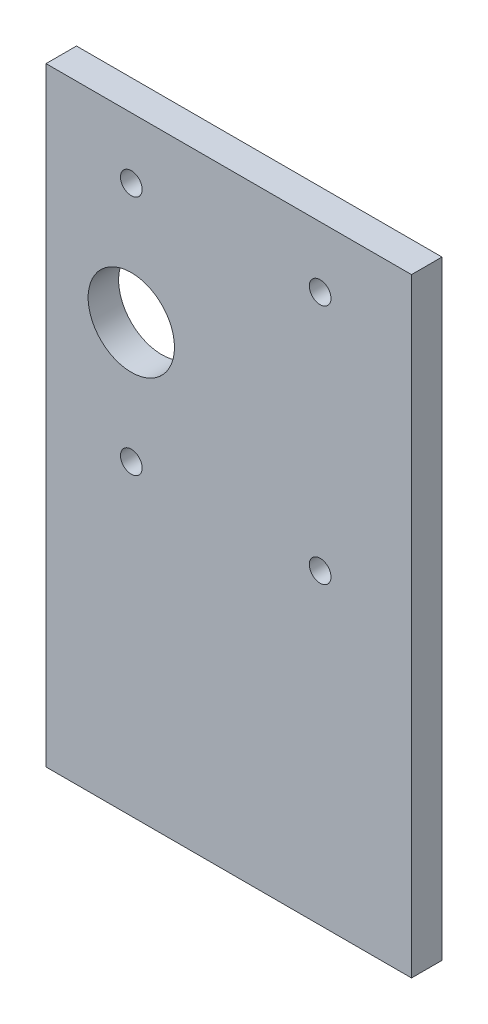
from build123d import *

# Parameters (mm, degrees)
SKETCH1_W             = 38.1
SKETCH1_H             = 63.5
BOSS_EXTRUDE1_DEPTH   = 3.175
F_4_40_TAPPED_HOLES_D = 2.2606
SKETCH5_R             = 4.5
CUT_EXTRUDE1_DEPTH    = 3.175


with BuildPart() as part:
    # Sketch1 → Boss-Extrude1 (new body)
    with BuildSketch(Plane.XY):
        with Locations((1.239118082, -20.003738635)):
            Rectangle(SKETCH1_W, SKETCH1_H)
    extrude(amount=BOSS_EXTRUDE1_DEPTH)

    # #4-40 Tapped Holes (through all)
    with Locations(Plane.XY.offset(3.175)):
        with Locations((-8.920881918, -19.749738635), (10.764118082, -19.749738635), (10.764118082, 5.396261365), (-8.920881918, 5.396261365)):
            Hole(F_4_40_TAPPED_HOLES_D / 2)

    # Sketch5 → Cut-Extrude1 (cut)
    with BuildSketch(Plane.XY.offset(3.175)):
        with Locations((-8.920881918, -7.176738635)):
            Circle(SKETCH5_R)
    extrude(amount=-CUT_EXTRUDE1_DEPTH, mode=Mode.SUBTRACT)


solid = part.part
